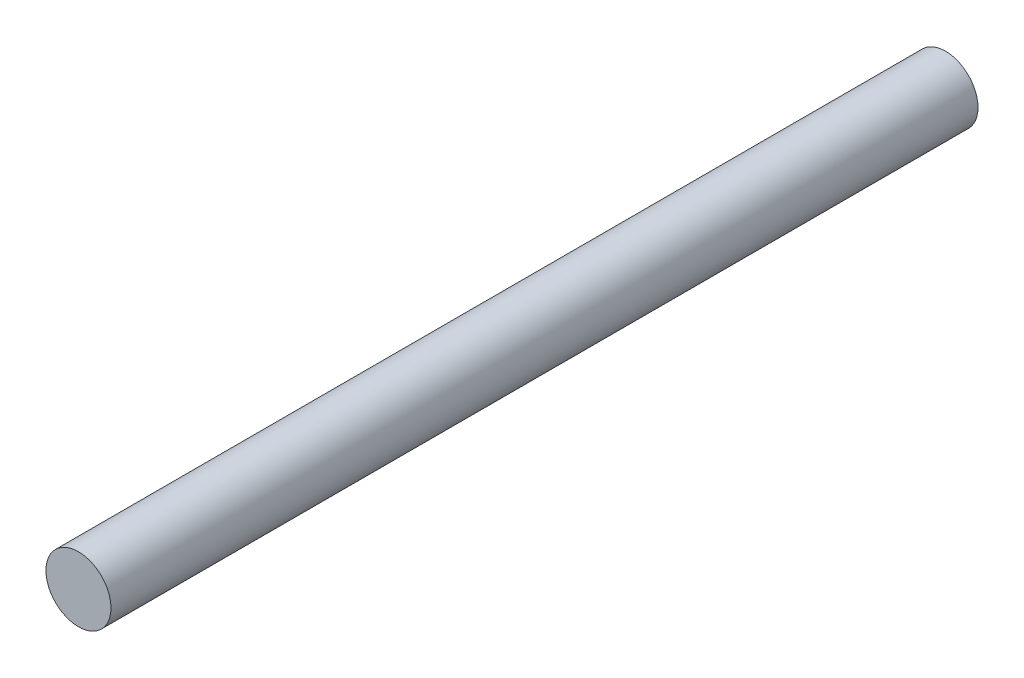
from build123d import *

# Parameters (mm, degrees)
SKETCH_1_R      = 1.5
EXTRUDE_1_DEPTH = 40


with BuildPart() as part:
    # 스케치1 → 보스-돌출1 (new body)
    with BuildSketch(Plane.XY):
        Circle(SKETCH_1_R)
    extrude(amount=EXTRUDE_1_DEPTH)


solid = part.part
